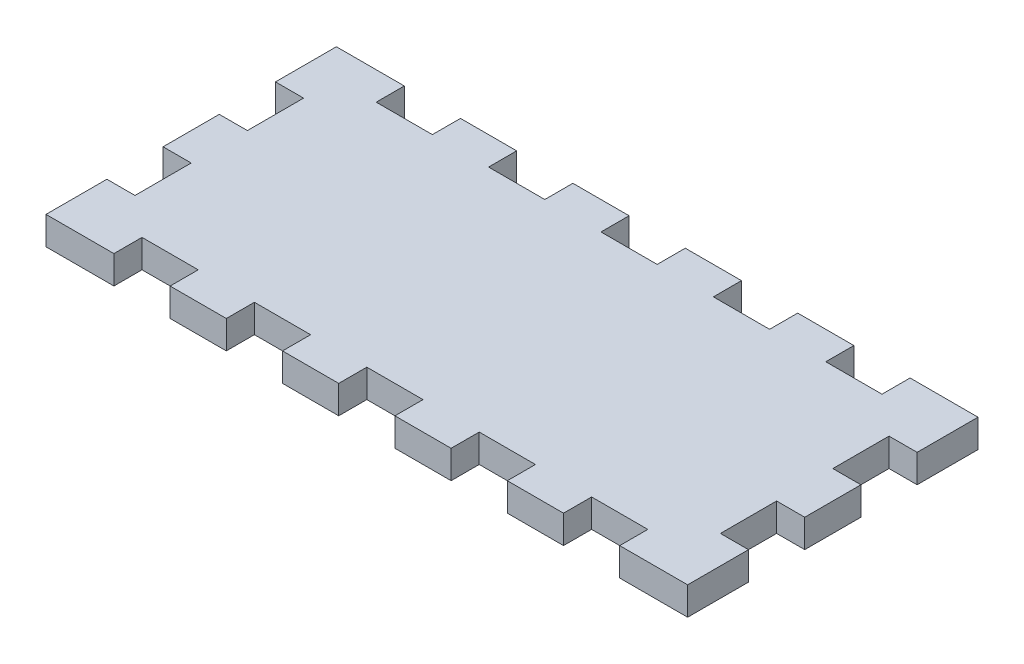
from build123d import *

# Parameters (mm, degrees)
BOSS_EXTRUDE1_DEPTH = 6


with BuildPart() as part:
    # Sketch1 → Boss-Extrude1 (new body)
    with BuildSketch(Plane(origin=(0, 0, 0), x_dir=(1, 0, 0), z_dir=(0, 1, 0))):
        Polygon((-54, -31), (-54, -25), (-42, -25), (-42, -31), (-30, -31), (-30, -25), (-18, -25), (-18, -31), (-6, -31), (-6, -25), (6, -25), (6, -31), (18, -31), (18, -25), (30, -25), (30, -31), (42, -31), (42, -25), (54, -25), (54, -31), (66, -31), (68.499999877, -31), (68.499999877, -17.999998649), (66.000000123, -17.999998649), (62.500000123, -17.999998649), (62.500000123, -5.999998649), (66.000000123, -5.999998649), (68.499999877, -5.999998649), (68.499999877, 6), (66.000000123, 6), (62.500000123, 6), (62.500000123, 18), (66.000000123, 18), (68.499999877, 18), (68.499999877, 31), (66, 31), (54, 31), (54, 25), (42, 25), (42, 31), (30, 31), (30, 25), (18, 25), (18, 31), (6, 31), (6, 25), (-6, 25), (-6, 31), (-18, 31), (-18, 25), (-30, 25), (-30, 31), (-42, 31), (-42, 25), (-54, 25), (-54, 31), (-66, 31), (-68.499999877, 31), (-68.499999877, 18), (-66.000000123, 18), (-62.500000123, 18), (-62.500000123, 6), (-66.000000123, 6), (-68.499999877, 6), (-68.499999877, -5.999998649), (-66.000000123, -5.999998649), (-62.500000123, -5.999998649), (-62.500000123, -17.999998649), (-66.000000123, -17.999998649), (-68.499999877, -17.999998649), (-68.499999877, -31), (-66, -31), align=None)
    extrude(amount=BOSS_EXTRUDE1_DEPTH)


solid = part.part
